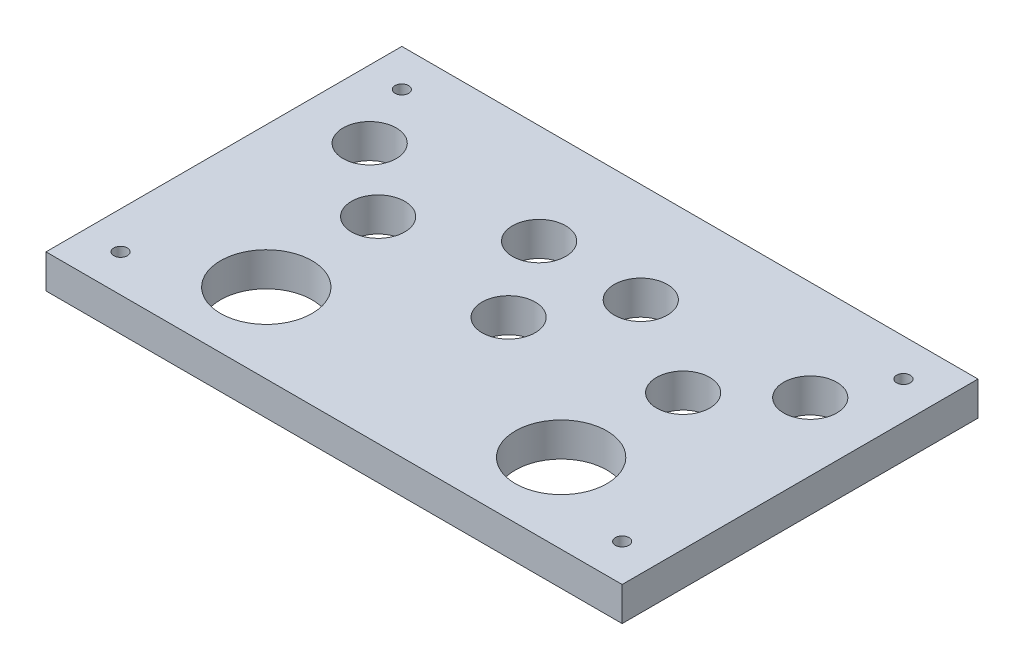
from build123d import *

# Parameters (mm, degrees)
SKETCH_1_W      = 170
SKETCH_1_H      = 105
SKETCH_1_R      = 2
SKETCH_1_R_2    = 13.5
SKETCH_1_R_3    = 7.85
EXTRUDE_1_DEPTH = 10


with BuildPart() as part:
    # ｽｹｯﾁ1 → ﾎﾞｽ - 押し出し1 (new body)
    with BuildSketch(Plane(origin=(0, 0, 0), x_dir=(1, 0, 0), z_dir=(0, 1, 0))):
        with Locations((85, 52.5)):
            Rectangle(SKETCH_1_W, SKETCH_1_H)
        with Locations((11, 94)):
            Circle(SKETCH_1_R, mode=Mode.SUBTRACT)
        with Locations((11, 11)):
            Circle(SKETCH_1_R, mode=Mode.SUBTRACT)
        with Locations((41.5, 23.5)):
            Circle(SKETCH_1_R_2, mode=Mode.SUBTRACT)
        with Locations((159, 11)):
            Circle(SKETCH_1_R, mode=Mode.SUBTRACT)
        with Locations((159, 94)):
            Circle(SKETCH_1_R, mode=Mode.SUBTRACT)
        with Locations((128.5, 23.5)):
            Circle(SKETCH_1_R_2, mode=Mode.SUBTRACT)
        with Locations((20, 75.5)):
            Circle(SKETCH_1_R_3, mode=Mode.SUBTRACT)
        with Locations((40, 58)):
            Circle(SKETCH_1_R_3, mode=Mode.SUBTRACT)
        with Locations((70, 75.5)):
            Circle(SKETCH_1_R_3, mode=Mode.SUBTRACT)
        with Locations((85, 51.5)):
            Circle(SKETCH_1_R_3, mode=Mode.SUBTRACT)
        with Locations((100, 75.5)):
            Circle(SKETCH_1_R_3, mode=Mode.SUBTRACT)
        with Locations((130, 58)):
            Circle(SKETCH_1_R_3, mode=Mode.SUBTRACT)
        with Locations((150, 75.5)):
            Circle(SKETCH_1_R_3, mode=Mode.SUBTRACT)
    extrude(amount=EXTRUDE_1_DEPTH)


solid = part.part
